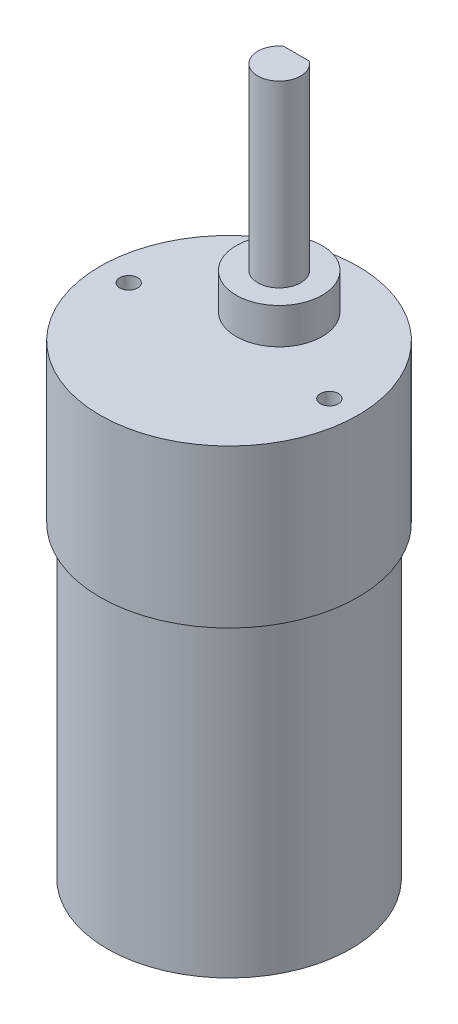
from build123d import *

# Parameters (mm, degrees)
ESQUISSE1_R                  = 17
BOSS_EXTRU_1_DEPTH           = 43
ESQUISSE2_R                  = 18
BOSS_EXTRU_2_DEPTH           = 22
ESQUISSE3_R                  = 6
BOSS_EXTRU_3_DEPTH           = 5
ESQUISSE4_R                  = 3
BOSS_EXTRU_4_DEPTH           = 25
ESQUISSE5_R                  = 1.25
ENL_V_MAT_EXTRU_1_DEPTH      = 5
ESQUISSE6_W                  = 15
ESQUISSE6_H                  = 5
BOSS_EXTRU_5_DEPTH           = 5
ENL_V_MAT_EXTRU_4_DEPTH      = 10
ENL_V_MAT_EXTRU_4_DEPTH_BACK = 22
ESQUISSE8_R                  = 5
BOSS_EXTRU_6_DEPTH           = 1
ESQUISSE9_R                  = 3.25
BOSS_EXTRU_7_DEPTH           = 4


with BuildPart() as part:
    # Esquisse1 → Boss.-Extru.1 (new body)
    with BuildSketch(Plane(origin=(0, 0, 0), x_dir=(1, 0, 0), z_dir=(0, 1, 0))):
        with Locations(Location((0, 0, 0), (0, 0, 270))):
            Circle(ESQUISSE1_R)
    extrude(amount=BOSS_EXTRU_1_DEPTH)

    # Esquisse2 → Boss.-Extru.2 (add)
    with BuildSketch(Plane(origin=(0, 43, 0), x_dir=(1, 0, 0), z_dir=(0, 1, 0))):
        with Locations(Location((0, 0, 0), (0, 0, 270))):
            Circle(ESQUISSE2_R)
    extrude(amount=BOSS_EXTRU_2_DEPTH)

    # Esquisse3 → Boss.-Extru.3 (add)
    with BuildSketch(Plane(origin=(0, 65, 0), x_dir=(1, 0, 0), z_dir=(0, 1, 0))):
        with Locations(Location((0, 7, 0), (0, 0, 270))):
            Circle(ESQUISSE3_R)
    extrude(amount=BOSS_EXTRU_3_DEPTH)

    # Esquisse4 → Boss.-Extru.4 (add)
    with BuildSketch(Plane(origin=(0, 70, 0), x_dir=(1, 0, 0), z_dir=(0, 1, 0))):
        with Locations(Location((0, 7, 0), (0, 0, 270))):
            Circle(ESQUISSE4_R)
    extrude(amount=BOSS_EXTRU_4_DEPTH)

    # Esquisse5 → Enlèv. mat.-Extru.1 (cut)
    with BuildSketch(Plane(origin=(0, 65, 0), x_dir=(1, 0, 0), z_dir=(0, 1, 0))):
        with Locations(Location((14, 0, 0), (0, 0, 270))):
            Circle(ESQUISSE5_R)
        with Locations(Location((-14, 0, 0), (0, 0, 270))):
            Circle(ESQUISSE5_R)
    extrude(amount=-ENL_V_MAT_EXTRU_1_DEPTH, mode=Mode.SUBTRACT)

    # Esquisse6 → Boss.-Extru.5 (add)
    with BuildSketch(Plane.XZ):
        with Locations((0, -10)):
            Rectangle(ESQUISSE6_W, ESQUISSE6_H)
    extrude(amount=BOSS_EXTRU_5_DEPTH)

    # Esquisse7 → Enlèv. mat.-Extru.4 (cut, two sides)
    with BuildSketch(Plane(origin=(0, 95, 0), x_dir=(1, 0, 0), z_dir=(0, 1, 0))) as enl_v_mat_extru_4_sk:
        with BuildLine():
            Line((-1.8, 9.4), (1.8, 9.4))
            ThreePointArc((1.8, 9.4), (0, 10), (-1.8, 9.4))
        make_face()
    extrude(amount=ENL_V_MAT_EXTRU_4_DEPTH, mode=Mode.SUBTRACT)
    extrude(enl_v_mat_extru_4_sk.sketch, amount=-ENL_V_MAT_EXTRU_4_DEPTH_BACK, mode=Mode.SUBTRACT)

    # Esquisse8 → Boss.-Extru.6 (add)
    with BuildSketch(Plane.XZ):
        with Locations(Location((0, 0, 0), (0, 0, 90))):
            Circle(ESQUISSE8_R)
    extrude(amount=BOSS_EXTRU_6_DEPTH)

    # Esquisse9 → Boss.-Extru.7 (add)
    with BuildSketch(Plane.XZ.offset(1)):
        with Locations(Location((0, 0, 0), (0, 0, 270))):
            Circle(ESQUISSE9_R)
    extrude(amount=BOSS_EXTRU_7_DEPTH)


solid = part.part
